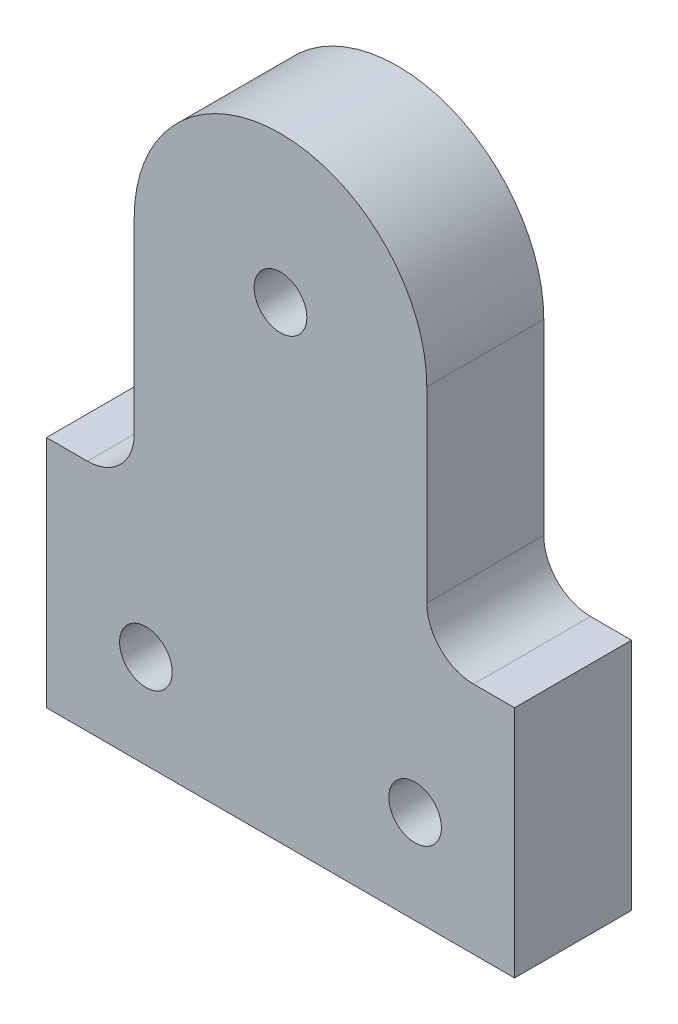
from build123d import *

# Parameters (mm, degrees)
SKETCH_1_R          = 2.25
EXTRUDE_1_DEPTH     = 10
CUT_EXTRUDE_1_DEPTH = 3


with BuildPart() as part:
    # 草图1 → 凸台-拉伸1 (new body)
    with BuildSketch(Plane.XY):
        with BuildLine():
            Line((-20, 12), (-20, -8))
            Line((-20, -8), (20, -8))
            Line((20, -8), (20, 12))
            Line((20, 12), (16.5, 12))
            ThreePointArc((16.5, 12), (13.671572875, 13.171572875), (12.5, 16))
            Line((12.5, 16), (12.5, 32))
            ThreePointArc((12.5, 32), (0, 44.5), (-12.5, 32))
            Line((-12.5, 32), (-12.5, 16))
            ThreePointArc((-12.5, 16), (-13.671572875, 13.171572875), (-16.5, 12))
            Line((-16.5, 12), (-20, 12))
        make_face()
        with Locations((-11.5, 0)):
            Circle(SKETCH_1_R, mode=Mode.SUBTRACT)
        with Locations((11.5, 0)):
            Circle(SKETCH_1_R, mode=Mode.SUBTRACT)
        with Locations((0, 32)):
            Circle(SKETCH_1_R, mode=Mode.SUBTRACT)
    extrude(amount=EXTRUDE_1_DEPTH)

    # 草图2 → 切除-拉伸1 (cut)
    with BuildSketch(Plane(origin=(0, 0, 0), x_dir=(-1, 0, 0), z_dir=(0, 0, -1))):
        Polygon((-11.5, -4.330127019), (-7.75, -2.165063509), (-7.75, 2.165063509), (-11.5, 4.330127019), (-15.25, 2.165063509), (-15.25, -2.165063509), align=None)
        Polygon((11.5, -4.330127019), (15.25, -2.165063509), (15.25, 2.165063509), (11.5, 4.330127019), (7.75, 2.165063509), (7.75, -2.165063509), align=None)
    extrude(amount=-CUT_EXTRUDE_1_DEPTH, mode=Mode.SUBTRACT)


solid = part.part
